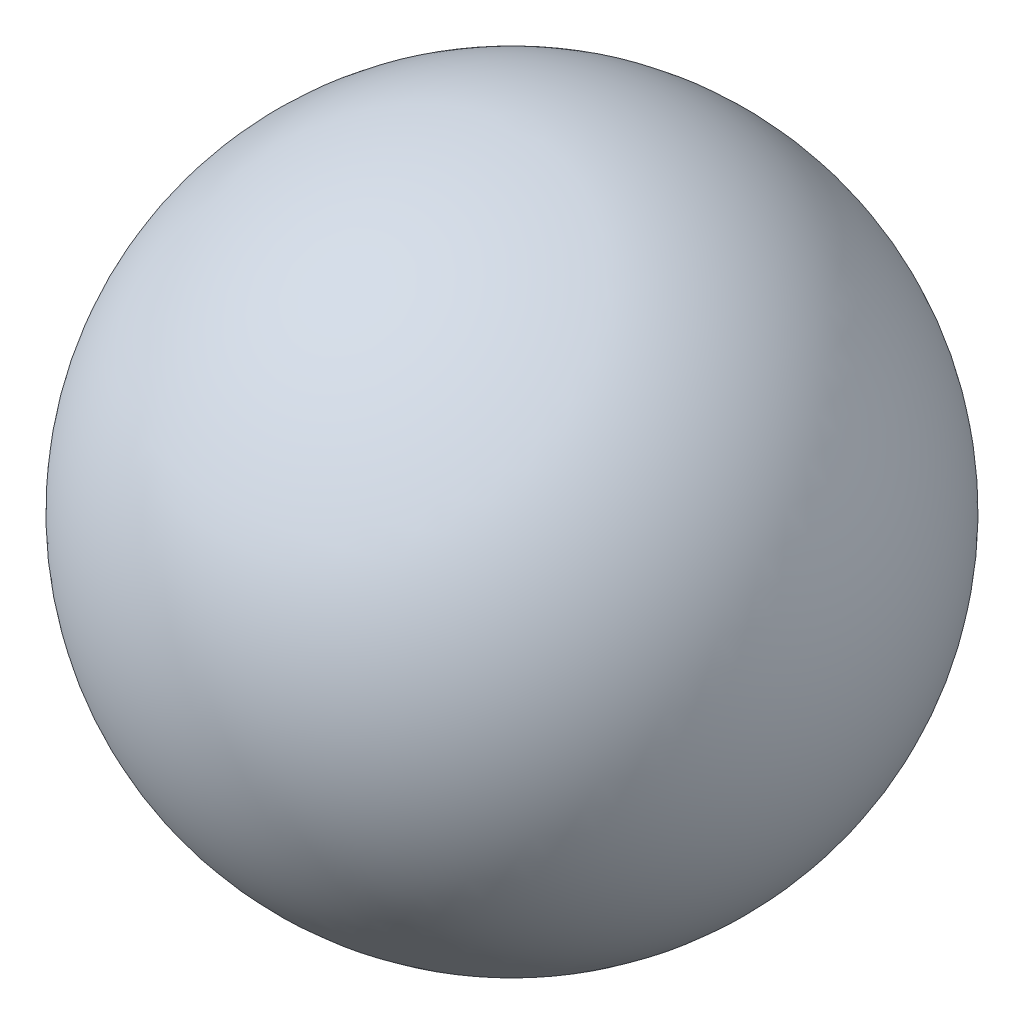
from build123d import *

# Parameters (mm, degrees)
SKETCH2_R          = 1.9
CUT_EXTRUDE1_DEPTH = 2.54


with BuildPart() as part:
    # Sketch1 → Revolve1 (revolve)
    with BuildSketch(Plane(origin=(0, 0, 0), x_dir=(0, 0, -1), z_dir=(1, 0, 0))):
        with BuildLine():
            Line((0, 141.137070307), (0, 139.637070307))
            ThreePointArc((0, 139.637070307), (69.584082777, 92.105902156), (50.616284989, 10))
            Line((50.616284989, 10), (31.75, 10))
            Line((31.75, 10), (31.75, 6))
            Line((31.75, 6), (39.87, 6))
            Line((39.87, 6), (39.87, 0))
            ThreePointArc((39.87, 0), (73.330228274, 85.652224695), (0, 141.137070307))
        make_face()
    revolve(axis=Axis((0, 141.137070307, 0), (0, -1, 0)))

    # Sketch2 → Cut-Extrude1 (cut)
    with BuildSketch(Plane.XZ.offset(-6)):
        with Locations((0, 35.56)):
            Circle(SKETCH2_R)
        with Locations((35.56, 0)):
            Circle(SKETCH2_R)
        with Locations((0, -35.56)):
            Circle(SKETCH2_R)
        with Locations((-35.56, 0)):
            Circle(SKETCH2_R)
    extrude(amount=-CUT_EXTRUDE1_DEPTH, mode=Mode.SUBTRACT)


solid = part.part
